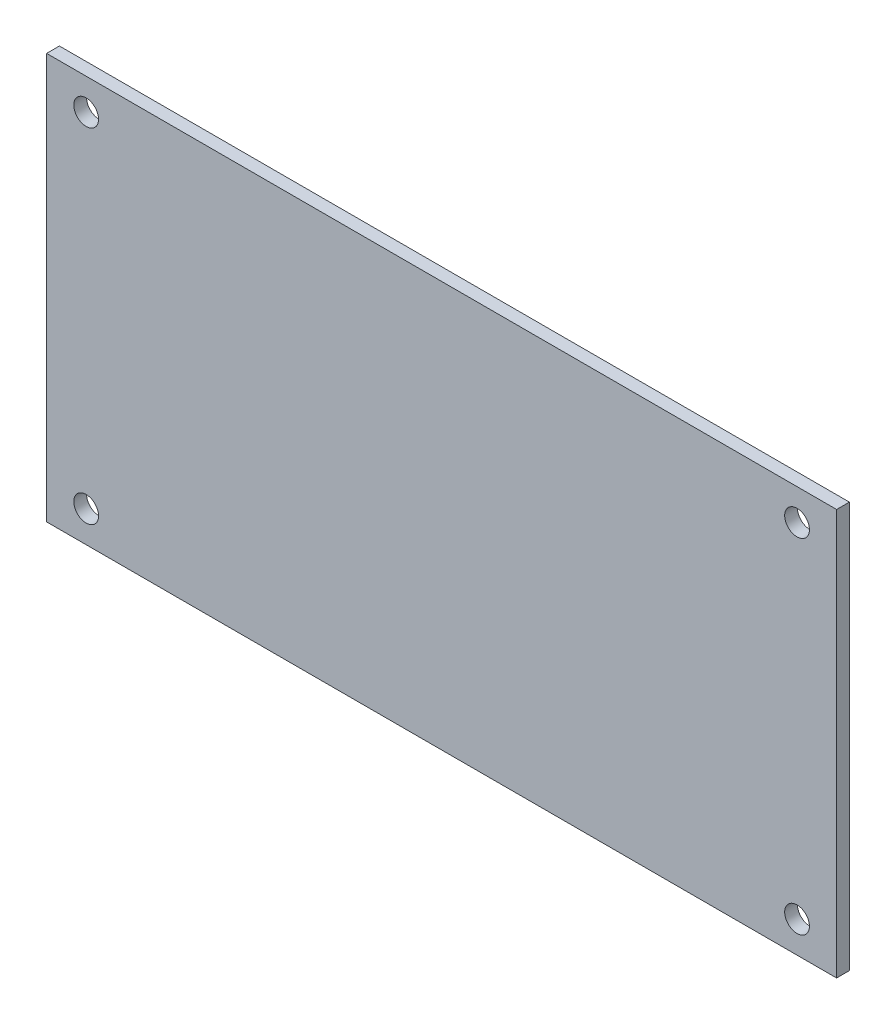
from build123d import *

# Parameters (mm, degrees)
SKETCH1_W           = 98.9
SKETCH1_H           = 50.8
SKETCH1_R           = 1.55
BOSS_EXTRUDE2_DEPTH = 1.6


with BuildPart() as part:
    # Sketch1 → Boss-Extrude2 (new body)
    with BuildSketch(Plane.XY):
        Rectangle(SKETCH1_W, SKETCH1_H)
        with Locations((-44.5, 21.5)):
            Circle(SKETCH1_R, mode=Mode.SUBTRACT)
        with Locations((44.5, 21.5)):
            Circle(SKETCH1_R, mode=Mode.SUBTRACT)
        with Locations((44.5, -21.5)):
            Circle(SKETCH1_R, mode=Mode.SUBTRACT)
        with Locations((-44.5, -21.5)):
            Circle(SKETCH1_R, mode=Mode.SUBTRACT)
    extrude(amount=BOSS_EXTRUDE2_DEPTH)


solid = part.part
